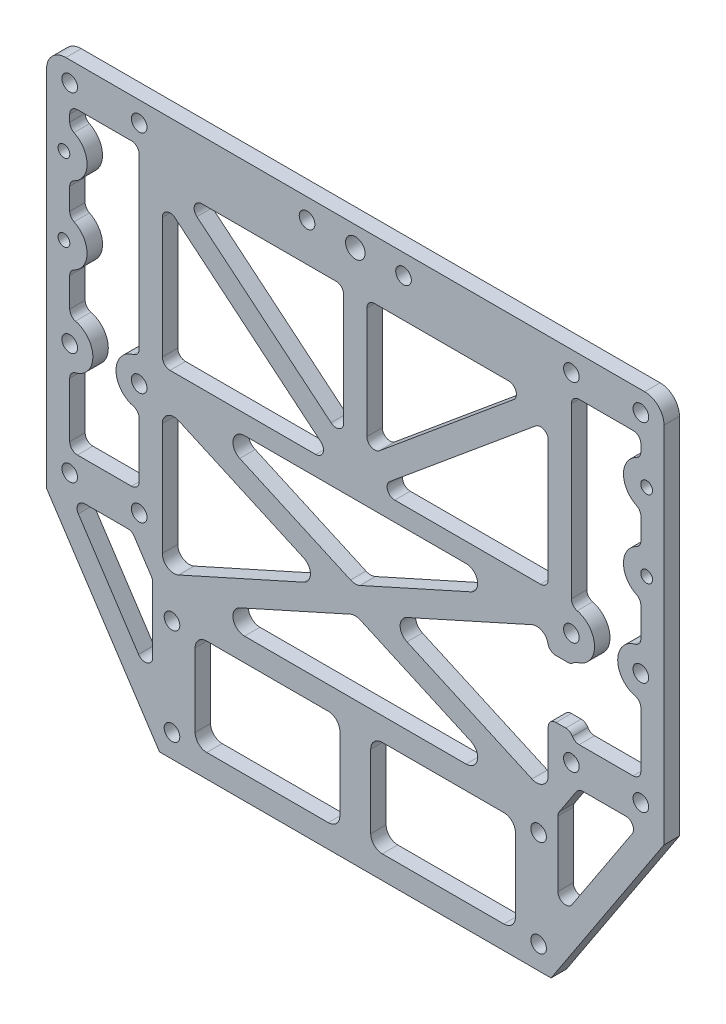
from build123d import *

# Parameters (mm, degrees)
SKETCH_1_R           = 2.025
EXTRUDE_1_DEPTH      = 4
SKETCH_2_R           = 2.025
CUT_EXTRUDE_1_DEPTH  = 10
SKETCH_3_R           = 2.525
CUT_EXTRUDE_2_DEPTH  = 10
SKETCH_4_W           = 37.5
SKETCH_4_H           = 25
CUT_EXTRUDE_3_DEPTH  = 10
FILLET_2_R           = 3
CUT_EXTRUDE_4_DEPTH  = 10
SKETCH_6_W           = 100
SKETCH_6_H           = 41.5
CUT_EXTRUDE_5_DEPTH  = 10
SKETCH_7_W           = 160
SKETCH_7_H           = 4.8
CUT_EXTRUDE_7_DEPTH  = 10
FILLET_5_R           = 5
EXTRUDE_2_DEPTH      = 4
FILLET_6_R           = 2
SKETCH_13_R          = 2.025
CUT_EXTRUDE_8_DEPTH  = 10
SKETCH_14_R          = 1.525
CUT_EXTRUDE_9_DEPTH  = 10
FILLET_7_R           = 5
SKETCH_15_W          = 7
SKETCH_15_H          = 15
CUT_EXTRUDE_10_DEPTH = 10
FILLET_8_R           = 2
EXTRUDE_3_DEPTH      = 4
FILLET_9_R           = 2


with BuildPart() as part:
    # 草图1 → 凸台-拉伸1 (new body)
    with BuildSketch(Plane.XY):
        Polygon((-80, 83), (-80, -21), (-50.735383462, -65.5), (50.735383462, -65.5), (80, -21), (80, 83), align=None)
        with Locations((74, -14.5)):
            Circle(SKETCH_1_R, mode=Mode.SUBTRACT)
        with Locations((-74, -14.5)):
            Circle(SKETCH_1_R, mode=Mode.SUBTRACT)
        with Locations((-74, 14.5)):
            Circle(SKETCH_1_R, mode=Mode.SUBTRACT)
        with Locations((-74, 73)):
            Circle(SKETCH_1_R, mode=Mode.SUBTRACT)
        with Locations((74, 14.5)):
            Circle(SKETCH_1_R, mode=Mode.SUBTRACT)
        with Locations((74, 73)):
            Circle(SKETCH_1_R, mode=Mode.SUBTRACT)
        with Locations((47.5, -34.5)):
            Circle(SKETCH_1_R, mode=Mode.SUBTRACT)
        with Locations((-47.5, -59.5)):
            Circle(SKETCH_1_R, mode=Mode.SUBTRACT)
        with Locations((-47.5, -34.5)):
            Circle(SKETCH_1_R, mode=Mode.SUBTRACT)
        with Locations((47.5, -59.5)):
            Circle(SKETCH_1_R, mode=Mode.SUBTRACT)
    extrude(amount=EXTRUDE_1_DEPTH)

    # 草图2 → 切除-拉伸1 (cut)
    with BuildSketch(Plane.XY.offset(4)):
        with Locations((-74, -14.5)):
            Circle(SKETCH_2_R)
        with Locations((-74, 14.5)):
            Circle(SKETCH_2_R)
        with Locations((-74, 73)):
            Circle(SKETCH_2_R)
        with Locations((-56, 73)):
            Circle(SKETCH_2_R)
        with Locations((-56, 14.5)):
            Circle(SKETCH_2_R)
        with Locations((-56, -14.5)):
            Circle(SKETCH_2_R)
        with Locations((56, -14.5)):
            Circle(SKETCH_2_R)
        with Locations((56, 14.5)):
            Circle(SKETCH_2_R)
        with Locations((56, 73)):
            Circle(SKETCH_2_R)
    extrude(amount=-CUT_EXTRUDE_1_DEPTH, mode=Mode.SUBTRACT)

    # 草图3 → 切除-拉伸2 (cut)
    with BuildSketch(Plane.XY.offset(4)):
        with Locations((0, 73)):
            Circle(SKETCH_3_R)
    extrude(amount=-CUT_EXTRUDE_2_DEPTH, mode=Mode.SUBTRACT)

    # 草图4 → 切除-拉伸3 (cut)
    with BuildSketch(Plane.XY.offset(4)):
        Polygon((-42.689429267, 16.5), (0, -2.71024317), (42.689429267, 16.5), align=None)
        Polygon((-50, -25.21024317), (-7.310570733, -6), (-50, 13.21024317), align=None)
        Polygon((50, 13.21024317), (7.310570733, -6), (50, -25.21024317), align=None)
        Polygon((0, -9.28975683), (-42.689429267, -28.5), (42.689429267, -28.5), align=None)
        with Locations((22.75, -47)):
            Rectangle(SKETCH_4_W, SKETCH_4_H)
        with Locations((-22.75, -47)):
            Rectangle(SKETCH_4_W, SKETCH_4_H)
    extrude(amount=-CUT_EXTRUDE_3_DEPTH, mode=Mode.SUBTRACT)

    # 圆角2
    fillet_2_edges = [part.edges().sort_by_distance(p)[0] for p in [
        (41.5, -59.5, 2),
        (4, -59.5, 2),
        (4, -34.5, 2),
        (41.5, -34.5, 2),
        (0, -9.28975683, 2),
        (42.689429267, -28.5, 2),
        (-42.689429267, -28.5, 2),
        (7.310570733, -6, 2),
        (50, 13.21024317, 2),
        (50, -25.21024317, 2),
        (-50, -25.21024317, 2),
        (-50, 13.21024317, 2),
        (-7.310570733, -6, 2),
        (-4, -59.5, 2),
        (-41.5, -59.5, 2),
        (-41.5, -34.5, 2),
        (-4, -34.5, 2),
        (-42.689429267, 16.5, 2),
        (42.689429267, 16.5, 2),
        (0, -2.71024317, 2),
    ]]
    fillet(fillet_2_edges, radius=FILLET_2_R)

    # 草图5 → 切除-拉伸4 (cut)
    with BuildSketch(Plane.XY.offset(4)):
        Polygon((-73.805273292, -19.5), (-57.885160349, -19.5), (-52.5, -27.688716064), (-52.5, -51.896961713), align=None)
        Polygon((52.5, -27.688716064), (52.5, -51.896961713), (73.805273292, -19.5), (57.885160349, -19.5), align=None)
    extrude(amount=-CUT_EXTRUDE_4_DEPTH, mode=Mode.SUBTRACT)

    # 草图6 → 切除-拉伸5 (cut)
    with BuildSketch(Plane.XY.offset(4)):
        with BuildLine():
            Line((-56, 68), (-74, 68))
            Line((-74, 68), (-74, 20.5))
            ThreePointArc((-74, 20.5), (-68, 14.5), (-74, 8.5))
            Line((-74, 8.5), (-74, -9.5))
            Line((-74, -9.5), (-56, -9.5))
            Line((-56, -9.5), (-56, 8.5))
            ThreePointArc((-56, 8.5), (-62, 14.5), (-56, 20.5))
            Line((-56, 20.5), (-56, 68))
        make_face()
        with BuildLine():
            Line((56, -9.5), (74, -9.5))
            Line((74, -9.5), (74, 8.5))
            ThreePointArc((74, 8.5), (68, 14.5), (74, 20.5))
            Line((74, 20.5), (74, 68))
            Line((74, 68), (56, 68))
            Line((56, 68), (56, 20.5))
            ThreePointArc((56, 20.5), (62, 14.5), (56, 8.5))
            Line((56, 8.5), (56, -9.5))
        make_face()
        with Locations((0, 42.25)):
            Rectangle(SKETCH_6_W, SKETCH_6_H)
    extrude(amount=-CUT_EXTRUDE_5_DEPTH, mode=Mode.SUBTRACT)

    # 草图7 → 切除-拉伸7 (cut)
    with BuildSketch(Plane.XY.offset(4)):
        with Locations((0, 80.6)):
            Rectangle(SKETCH_7_W, SKETCH_7_H)
    extrude(amount=-CUT_EXTRUDE_7_DEPTH, mode=Mode.SUBTRACT)

    # 圆角5
    fillet_5_edges = [part.edges().sort_by_distance(p)[0] for p in [
        (-80, 78.2, 2),
        (80, 78.2, 2),
    ]]
    fillet(fillet_5_edges, radius=FILLET_5_R)

    # 草图11 → 凸台-拉伸2 (add)
    with BuildSketch(Plane.XY.offset(4)):
        Polygon((-50, 63), (-50, 59.101269437), (-4.697265738, 21.5), (4.697265738, 21.5), (50, 59.101269437), (50, 63), (45.302734262, 63), (3, 27.888730563), (3, 63), (-3, 63), (-3, 27.888730563), (-45.302734262, 63), align=None)
    extrude(amount=-EXTRUDE_2_DEPTH)

    # 圆角6
    fillet_6_edges = [part.edges().sort_by_distance(p)[0] for p in [
        (-52.5, -51.896961713, 2),
        (-73.805273292, -19.5, 2),
        (-57.885160349, -19.5, 2),
        (-52.5, -27.688716064, 2),
        (52.5, -27.688716064, 2),
        (57.885160349, -19.5, 2),
        (73.805273292, -19.5, 2),
        (52.5, -51.896961713, 2),
        (74, 20.5, 2),
        (74, 8.5, 2),
        (74, -9.5, 2),
        (56, -9.5, 2),
        (56, 8.5, 2),
        (56, 20.5, 2),
        (56, 68, 2),
        (74, 68, 2),
        (-56, 20.5, 2),
        (-56, 8.5, 2),
        (-56, -9.5, 2),
        (-74, -9.5, 2),
        (-74, 8.5, 2),
        (-74, 20.5, 2),
        (-74, 68, 2),
        (-56, 68, 2),
        (50, 21.5, 2),
        (-50, 21.5, 2),
        (4.697265738, 21.5, 2),
        (-4.697265738, 21.5, 2),
        (-50, 59.101269437, 2),
        (-45.302734262, 63, 2),
        (-3, 27.888730563, 2),
        (-3, 63, 2),
        (3, 63, 2),
        (3, 27.888730563, 2),
        (45.302734262, 63, 2),
        (50, 59.101269437, 2),
    ]]
    fillet(fillet_6_edges, radius=FILLET_6_R)

    # 草图13 → 切除-拉伸8 (cut)
    with BuildSketch(Plane.XY.offset(4)):
        with Locations((-12.5, 73)):
            Circle(SKETCH_13_R)
        with Locations((12.5, 73)):
            Circle(SKETCH_13_R)
    extrude(amount=-CUT_EXTRUDE_8_DEPTH, mode=Mode.SUBTRACT)

    # 草图14 → 切除-拉伸9 (cut)
    with BuildSketch(Plane.XY.offset(4)):
        with Locations((75.5, 37)):
            Circle(SKETCH_14_R)
        with Locations((75.5, 57)):
            Circle(SKETCH_14_R)
        with Locations((-75.5, 57)):
            Circle(SKETCH_14_R)
        with Locations((-75.5, 37)):
            Circle(SKETCH_14_R)
    extrude(amount=-CUT_EXTRUDE_9_DEPTH, mode=Mode.SUBTRACT)

    # 圆角7
    fillet_7_edges = [part.edges().sort_by_distance(p)[0] for p in [
        (74, 37.275, 2),
        (74, 36.725, 2),
        (74, 57.275, 2),
        (74, 56.725, 2),
        (-74, 57.275, 2),
        (-74, 56.725, 2),
        (-74, 37.275, 2),
        (-74, 36.725, 2),
    ]]
    fillet(fillet_7_edges, radius=FILLET_7_R)

    # 草图15 → 切除-拉伸10 (cut)
    with BuildSketch(Plane(origin=(0, 0, 0), x_dir=(-1, 0, 0), z_dir=(0, 0, -1))):
        with Locations((-53.5, 0)):
            Rectangle(SKETCH_15_W, SKETCH_15_H)
    extrude(amount=-CUT_EXTRUDE_10_DEPTH, mode=Mode.SUBTRACT)

    # 圆角8
    fillet_8_edges = [part.edges().sort_by_distance(p)[0] for p in [
        (56, -7.5, 2),
        (56.144323925, 7.5, 2),
        (50, -7.5, 2),
        (50, 7.5, 2),
    ]]
    fillet(fillet_8_edges, radius=FILLET_8_R)

    # 草图16 → 凸台-拉伸3 (add)
    with BuildSketch(Plane(origin=(0, 0, 0), x_dir=(-1, 0, 0), z_dir=(0, 0, -1))):
        with BuildLine():
            ThreePointArc((-76.318007663, 55.712953589), (-74.617651218, 53.900413894), (-74, 51.493129292))
            Line((-74, 51.493129292), (-74, 51.190524981))
            ThreePointArc((-74, 51.190524981), (-69.5, 57), (-74, 62.809475019))
            Line((-74, 62.809475019), (-74, 62.506870708))
            ThreePointArc((-74, 62.506870708), (-74.617651218, 60.099586106), (-76.318007663, 58.287046411))
            ThreePointArc((-76.318007663, 58.287046411), (-73.975, 57), (-76.318007663, 55.712953589))
        make_face()
        with BuildLine():
            ThreePointArc((-74, 31.190524981), (-69.5, 37), (-74, 42.809475019))
            Line((-74, 42.809475019), (-74, 42.506870708))
            ThreePointArc((-74, 42.506870708), (-74.617651218, 40.099586106), (-76.318007663, 38.287046411))
            ThreePointArc((-76.318007663, 38.287046411), (-73.975, 37), (-76.318007663, 35.712953589))
            ThreePointArc((-76.318007663, 35.712953589), (-74.617651218, 33.900413894), (-74, 31.493129292))
            Line((-74, 31.493129292), (-74, 31.190524981))
        make_face()
        with BuildLine():
            Line((74, 31.190524981), (74, 31.493129292))
            ThreePointArc((74, 31.493129292), (74.617651218, 33.900413894), (76.318007663, 35.712953589))
            ThreePointArc((76.318007663, 35.712953589), (73.975, 37), (76.318007663, 38.287046411))
            ThreePointArc((76.318007663, 38.287046411), (74.617651218, 40.099586106), (74, 42.506870708))
            Line((74, 42.506870708), (74, 42.809475019))
            ThreePointArc((74, 42.809475019), (69.5, 37), (74, 31.190524981))
        make_face()
        with BuildLine():
            ThreePointArc((74, 62.809475019), (69.5, 57), (74, 51.190524981))
            Line((74, 51.190524981), (74, 51.493129292))
            ThreePointArc((74, 51.493129292), (74.617651218, 53.900413894), (76.318007663, 55.712953589))
            ThreePointArc((76.318007663, 55.712953589), (73.975, 57), (76.318007663, 58.287046411))
            ThreePointArc((76.318007663, 58.287046411), (74.617651218, 60.099586106), (74, 62.506870708))
            Line((74, 62.506870708), (74, 62.809475019))
        make_face()
    extrude(amount=-EXTRUDE_3_DEPTH)

    # 圆角9
    fillet_9_edges = [part.edges().sort_by_distance(p)[0] for p in [
        (74, 62.809475019, 2),
        (74, 51.190524981, 2),
        (74, 42.809475019, 2),
        (74, 31.190524981, 2),
        (-74, 42.809475019, 2),
        (-74, 31.190524981, 2),
        (-74, 62.809475019, 2),
        (-74, 51.190524981, 2),
    ]]
    fillet(fillet_9_edges, radius=FILLET_9_R)


solid = part.part
